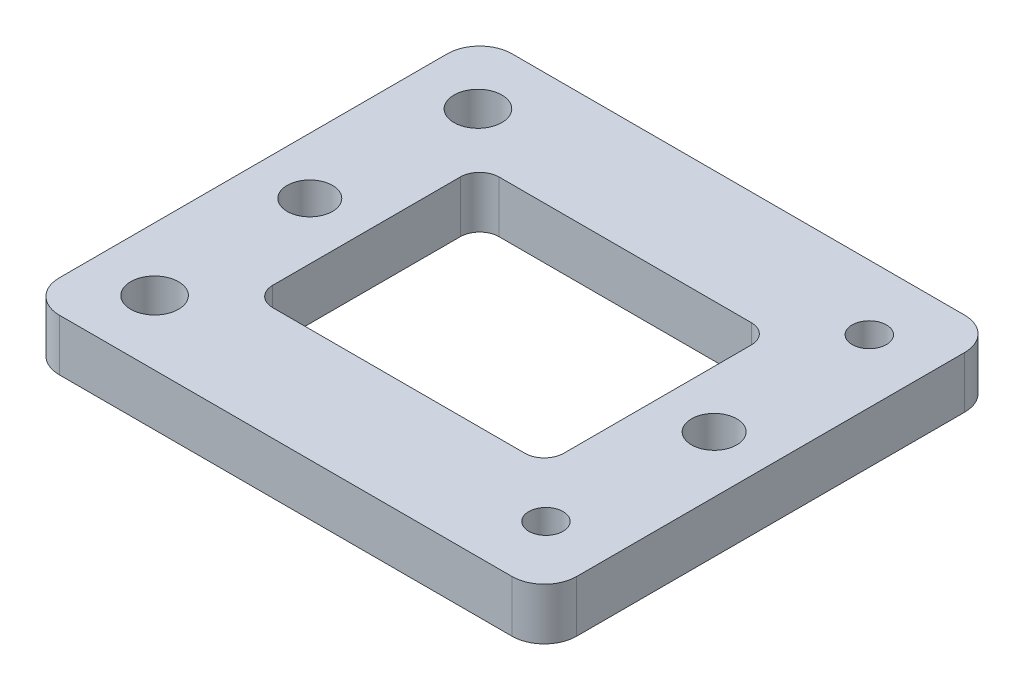
from build123d import *

# Parameters (mm, degrees)
CROQUIS1_R              = 3.5
CROQUIS1_R_2            = 2.65
CROQUIS1_R_3            = 3.7
SALIENTE_EXTRUIR2_DEPTH = 8


with BuildPart() as part:
    # Croquis1 → Saliente-Extruir2 (new body)
    with BuildSketch(Plane(origin=(0, 0, 0), x_dir=(1, 0, 0), z_dir=(0, 1, 0))):
        with BuildLine():
            ThreePointArc((40, -30), (38.535533906, -33.535533906), (35, -35))
            Line((35, -35), (-35, -35))
            ThreePointArc((-35, -35), (-38.535533906, -33.535533906), (-40, -30))
            Line((-40, -30), (-40, 30))
            ThreePointArc((-40, 30), (-38.535533906, 33.535533906), (-35, 35))
            Line((-35, 35), (35, 35))
            ThreePointArc((35, 35), (38.535533906, 33.535533906), (40, 30))
            Line((40, 30), (40, -30))
        make_face()
        with Locations((31.259169622, 0)):
            Circle(CROQUIS1_R, mode=Mode.SUBTRACT)
        with Locations((30.25001, 25)):
            Circle(CROQUIS1_R_2, mode=Mode.SUBTRACT)
        with Locations((30.25001, -25)):
            Circle(CROQUIS1_R_2, mode=Mode.SUBTRACT)
        with Locations((-31.263846279, 0)):
            Circle(CROQUIS1_R, mode=Mode.SUBTRACT)
        with Locations((-30.264120004, 24.99741)):
            Circle(CROQUIS1_R_3, mode=Mode.SUBTRACT)
        with Locations((-30.264120004, -25.00224)):
            Circle(CROQUIS1_R_3, mode=Mode.SUBTRACT)
        with BuildLine():
            ThreePointArc((19.5, -17.5), (21.621320344, -16.621320344), (22.5, -14.5))
            Line((22.5, -14.5), (22.5, 14.5))
            ThreePointArc((22.5, 14.5), (21.621320344, 16.621320344), (19.5, 17.5))
            Line((19.5, 17.5), (-19.5, 17.5))
            ThreePointArc((-19.5, 17.5), (-21.621320344, 16.621320344), (-22.5, 14.5))
            Line((-22.5, 14.5), (-22.5, -14.5))
            ThreePointArc((-22.5, -14.5), (-21.621320344, -16.621320344), (-19.5, -17.5))
            Line((-19.5, -17.5), (19.5, -17.5))
        make_face(mode=Mode.SUBTRACT)
    extrude(amount=SALIENTE_EXTRUIR2_DEPTH)


solid = part.part
